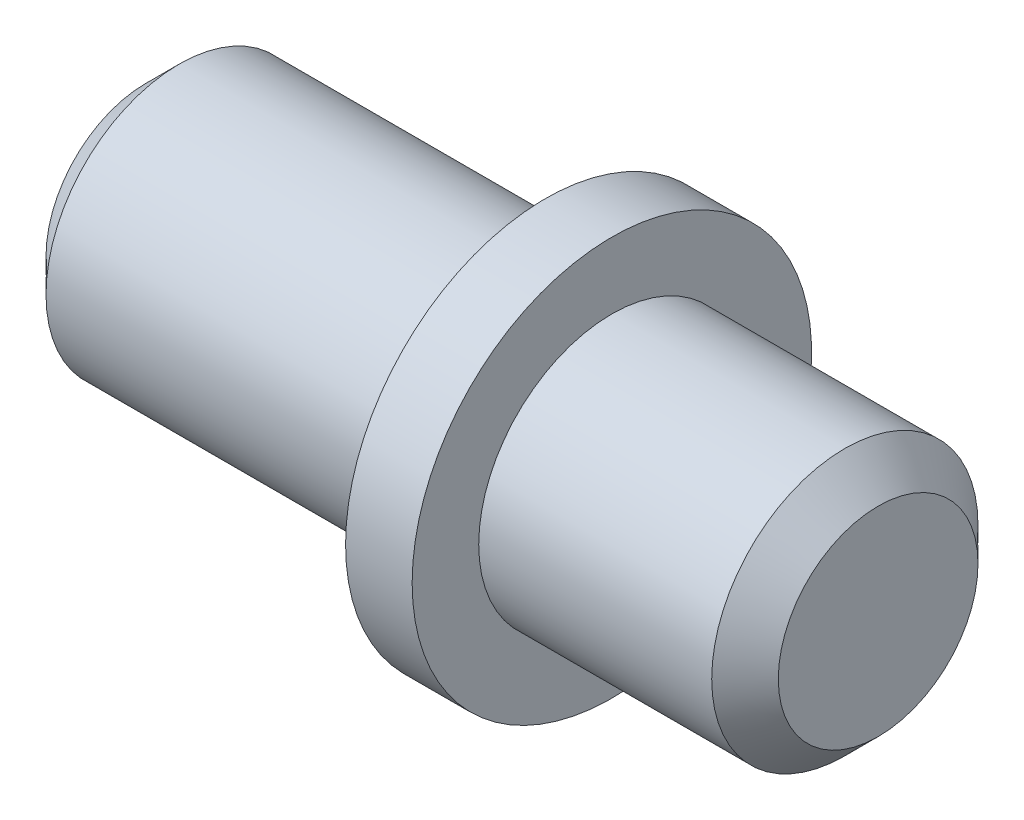
from build123d import *

# Parameters (mm, degrees)
CHANFREIN1_SIZE = 0.5


with BuildPart() as part:
    # Esquisse1 → Révolution1 (revolve)
    with BuildSketch(Plane.XY, mode=Mode.PRIVATE) as r_volution1_sk:
        Polygon((0, 0), (0, 2), (-4, 2), (-4, 3), (-5, 3), (-5, 2), (-11, 2), (-11, 0), align=None)
    revolve(r_volution1_sk.sketch.rotate(Axis((0, 0, 0), (1, 0, 0)), 90), axis=Axis((0, 0, 0), (1, 0, 0)))  # turned: the seam where the file's is

    # Chanfrein1
    chanfrein1_edges = [part.edges().sort_by_distance(p)[0] for p in [
        (-11, 0, -2),
        (0, 0, -2),
    ]]
    chamfer(chanfrein1_edges, length=CHANFREIN1_SIZE)


solid = part.part
